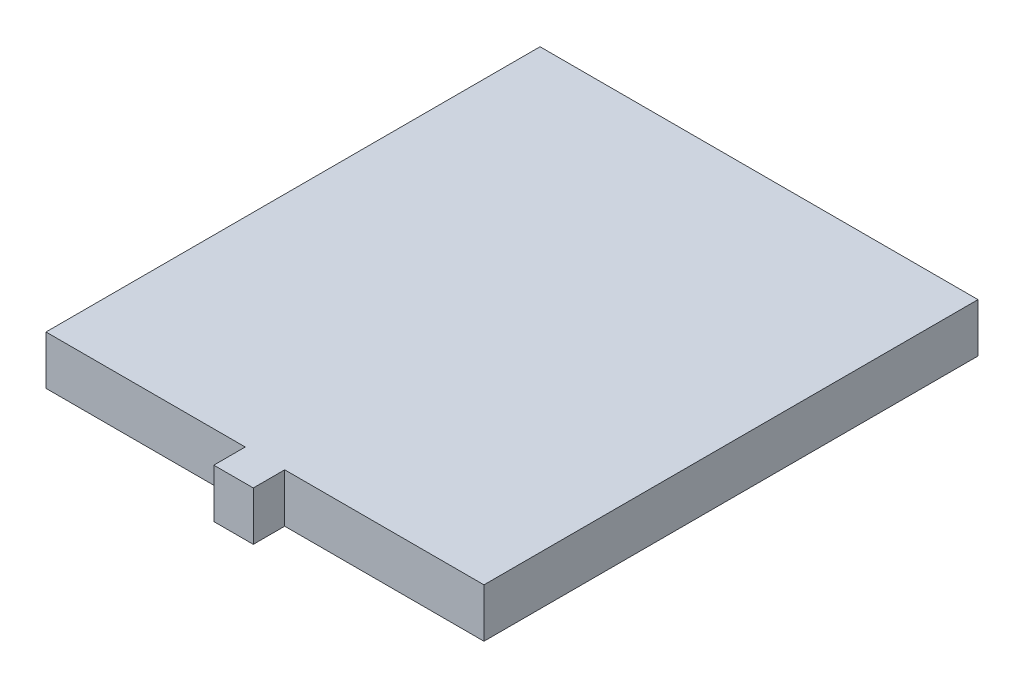
from build123d import *

# Parameters (mm, degrees)
SKETCH1_W           = 4.740543004
SKETCH1_H           = 3.773196038
SKETCH1_W_2         = 52.578
SKETCH1_H_2         = 59.309
BOSS_EXTRUDE1_DEPTH = 5.8674


with BuildPart() as part:
    # Sketch1 → Boss-Extrude1 (new body)
    with BuildSketch(Plane(origin=(0, 0, 0), x_dir=(1, 0, 0), z_dir=(0, 1, 0))):
        with Locations((-16.434014347, -34.546753615)):
            Rectangle(SKETCH1_W, SKETCH1_H)
        with Locations((-16.434014347, -3.005655596)):
            Rectangle(SKETCH1_W_2, SKETCH1_H_2)
    extrude(amount=BOSS_EXTRUDE1_DEPTH)


solid = part.part
